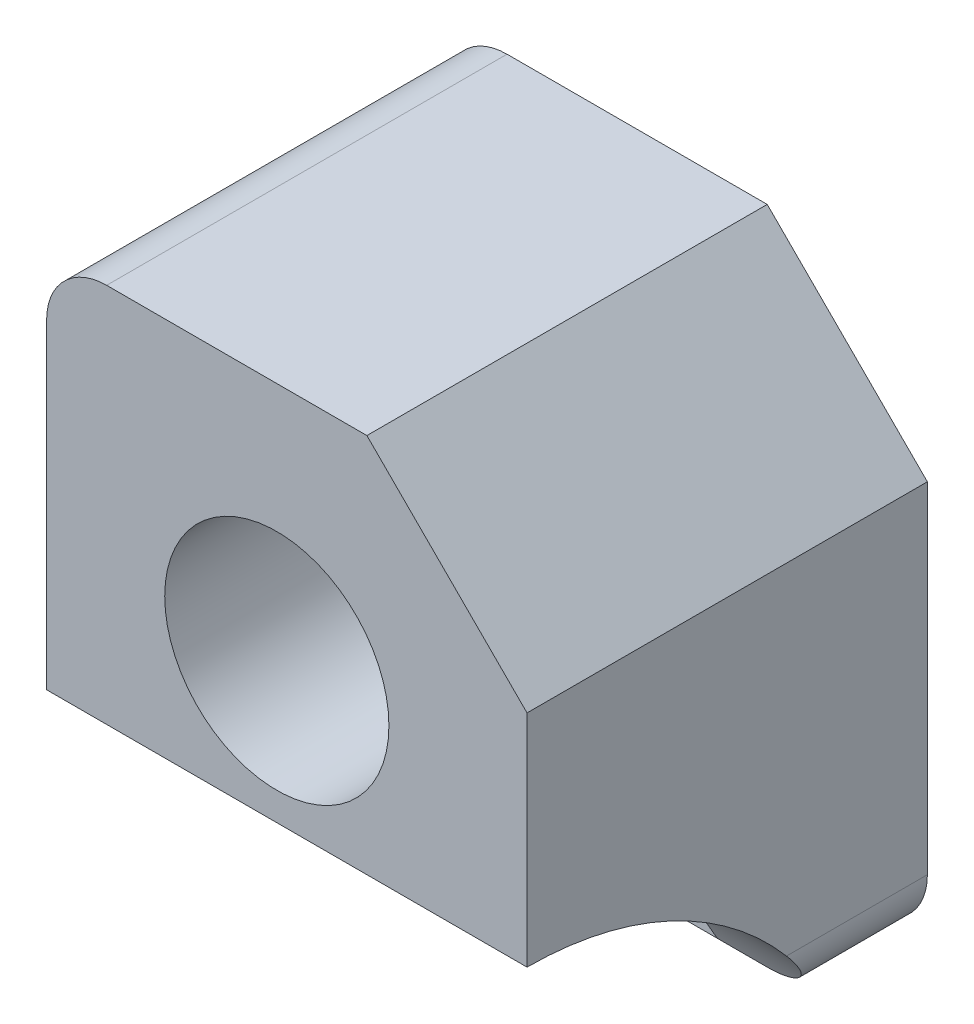
from build123d import *

# Parameters (mm, degrees)
SKETCH1_R           = 2
SKETCH1_R_2         = 5.6
BOSS_EXTRUDE1_DEPTH = 20
CUT_EXTRUDE1_DEPTH  = 30
CUT_EXTRUDE2_DEPTH  = 15
FILLET1_R           = 3


with BuildPart() as part:
    # Sketch1 → Boss-Extrude1 (new body)
    with BuildSketch(Plane.XY):
        Polygon((24, 20), (16, 28), (0, 28), (0, 0), (24, 0), align=None)
        with Locations((4, 4)):
            Circle(SKETCH1_R, mode=Mode.SUBTRACT)
        with Locations((14, 4)):
            Circle(SKETCH1_R, mode=Mode.SUBTRACT)
        with Locations((11.5, 16)):
            Circle(SKETCH1_R_2, mode=Mode.SUBTRACT)
    extrude(amount=BOSS_EXTRUDE1_DEPTH)

    # Sketch2 → Cut-Extrude1 (cut)
    with BuildSketch(Plane.ZY):
        with BuildLine():
            Line((20, 9), (20, 0))
            Line((20, 0), (5, 0))
            ThreePointArc((5, 0), (11.253572158, 6.577379737), (20, 9))
        make_face()
    extrude(amount=-CUT_EXTRUDE1_DEPTH, mode=Mode.SUBTRACT)

    # Sketch3 → Cut-Extrude2 (cut)
    with BuildSketch(Plane.XY.offset(20)):
        with BuildLine():
            ThreePointArc((14, -0.5), (17.181980515, 0.818019485), (18.5, 4))
            Line((18.5, 4), (9.5, 4))
            ThreePointArc((9.5, 4), (10.818019485, 0.818019485), (14, -0.5))
        make_face()
        with BuildLine():
            Line((9.5, 4), (18.5, 4))
            ThreePointArc((18.5, 4), (14, 8.5), (9.5, 4))
        make_face()
        with BuildLine():
            ThreePointArc((14, -0.5), (10.818019485, 0.818019485), (9.5, 4))
            Line((9.5, 4), (9.5, -0.5))
            Line((9.5, -0.5), (14, -0.5))
        make_face()
        with BuildLine():
            Line((18.5, -0.5), (18.5, 4))
            ThreePointArc((18.5, 4), (17.181980515, 0.818019485), (14, -0.5))
            Line((14, -0.5), (18.5, -0.5))
        make_face()
        with BuildLine():
            ThreePointArc((4, -0.5), (7.181980515, 0.818019485), (8.5, 4))
            Line((8.5, 4), (0, 4))
            Line((0, 4), (0, 1.938447187))
            ThreePointArc((0, 1.938447187), (1.657670781, 0.157670781), (4, -0.5))
        make_face()
        with BuildLine():
            Line((0, 4), (8.5, 4))
            ThreePointArc((8.5, 4), (2.939339828, 8.373213921), (0, 1.938447187))
            Line((0, 1.938447187), (0, 4))
        make_face()
        with BuildLine():
            Line((8.5, -0.5), (8.5, 4))
            ThreePointArc((8.5, 4), (7.181980515, 0.818019485), (4, -0.5))
            Line((4, -0.5), (8.5, -0.5))
        make_face()
        with BuildLine():
            ThreePointArc((4, -0.5), (1.657670781, 0.157670781), (0, 1.938447187))
            Line((0, 1.938447187), (0, -0.5))
            Line((0, -0.5), (4, -0.5))
        make_face()
    extrude(amount=-CUT_EXTRUDE2_DEPTH, mode=Mode.SUBTRACT)

    # Fillet1
    fillet1_edges = [part.edges().sort_by_distance(p)[0] for p in [
        (0, 28, 10),
        (0, 0, 2.5),
        (24, 0, 2.5),
    ]]
    fillet(fillet1_edges, radius=FILLET1_R)


solid = part.part
